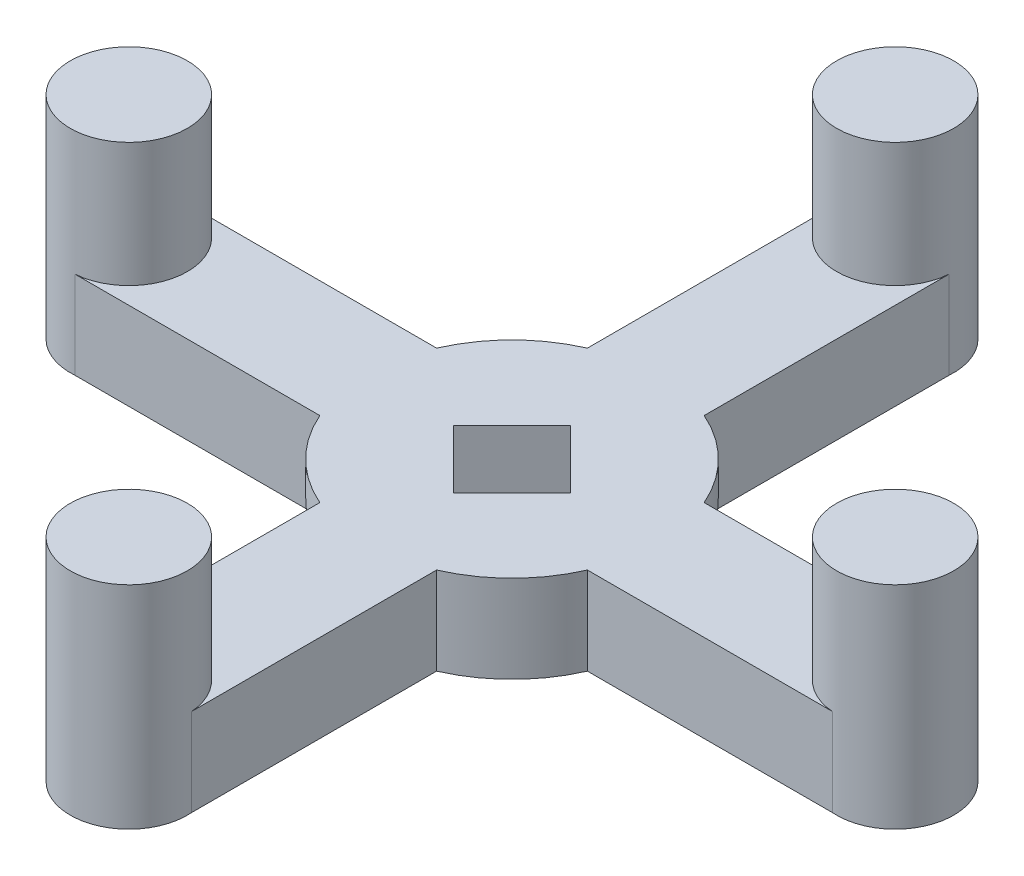
from build123d import *

# Parameters (mm, degrees)
BOSS_EXTRU_1_DEPTH           = 3
BOSS_EXTRU_1_DEPTH_BACK      = 3
BOSS_EXTRU_2_START           = -6
ESQUISSE2_R                  = 4.01172956
BOSS_EXTRU_2_DEPTH           = 14.5
R_P_TITION_CIRCULAIRE1_COUNT = 4
ENL_V_MAT_EXTRU_1_DEPTH      = 45.314721616
ENL_V_MAT_EXTRU_1_DEPTH_BACK = 45.314721616
ESQUISSE3_R                  = 1.05
ENL_V_MAT_EXTRU_2_DEPTH      = 45.314721616
ENL_V_MAT_EXTRU_2_DEPTH_BACK = 45.314721616


with BuildPart() as part:
    # Esquisse1 → Boss.-Extru.1 (new, two sides: drawn at the far end of the back side and taken through both)
    with BuildSketch(Plane(origin=(0, 0, 0), x_dir=(1, 0, 0), z_dir=(0, 1, 0)).offset(-BOSS_EXTRU_1_DEPTH_BACK)):
        with BuildLine():
            Line((4, -25.943448113), (4, -9.16515139))
            ThreePointArc((4, -9.16515139), (7.071067812, -7.071067812), (9.16515139, -4))
            Line((9.16515139, -4), (25.943448113, -4))
            ThreePointArc((25.943448113, -4), (26.25, 0), (25.943448113, 4))
            Line((25.943448113, 4), (9.16515139, 4))
            ThreePointArc((9.16515139, 4), (7.071067812, 7.071067812), (4, 9.16515139))
            Line((4, 9.16515139), (4, 25.943448113))
            ThreePointArc((4, 25.943448113), (0, 26.25), (-4, 25.943448113))
            Line((-4, 25.943448113), (-4, 9.16515139))
            ThreePointArc((-4, 9.16515139), (-7.071067812, 7.071067812), (-9.16515139, 4))
            Line((-9.16515139, 4), (-25.943448113, 4))
            ThreePointArc((-25.943448113, 4), (-26.25, 0), (-25.943448113, -4))
            Line((-25.943448113, -4), (-9.16515139, -4))
            ThreePointArc((-9.16515139, -4), (-7.071067812, -7.071067812), (-4, -9.16515139))
            Line((-4, -9.16515139), (-4, -25.943448113))
            ThreePointArc((-4, -25.943448113), (0, -26.25), (4, -25.943448113))
        make_face()
    extrude(amount=BOSS_EXTRU_1_DEPTH + BOSS_EXTRU_1_DEPTH_BACK)

    # Esquisse2 → Boss.-Extru.2 (add)
    with BuildSketch(Plane(origin=(0, 3, 0), x_dir=(1, 0, 0), z_dir=(0, 1, 0)).offset(BOSS_EXTRU_2_START)):
        with Locations((0, 26.25)):
            Circle(ESQUISSE2_R)
    boss_extru_2 = extrude(amount=BOSS_EXTRU_2_DEPTH)

    # Répétition circulaire1: Boss.-Extru.2 ×4 about axis
    r_p_tition_circulaire1_axis = Axis((0, 3, 0), (0, 1, 0))
    for i in range(1, R_P_TITION_CIRCULAIRE1_COUNT):
        add(boss_extru_2.rotate(r_p_tition_circulaire1_axis, i * 360 / R_P_TITION_CIRCULAIRE1_COUNT))

    # Esquisse3 → Enlèv. mat.-Extru.1 (cut, two sides: drawn at the far end of the back side and taken through both)
    with BuildSketch(Plane(origin=(0, 0, 0), x_dir=(-0.7071067811865477, 0, -0.7071067811865475), z_dir=(0.7071067811865475, 0, -0.7071067811865477)).offset(-ENL_V_MAT_EXTRU_1_DEPTH_BACK)):
        Circle(ESQUISSE3_R)
    extrude(amount=ENL_V_MAT_EXTRU_1_DEPTH + ENL_V_MAT_EXTRU_1_DEPTH_BACK, mode=Mode.SUBTRACT)

    # Esquisse4 → Enlèv. mat.-Extru.2 (cut, two sides: drawn at the far end of the back side and taken through both)
    with BuildSketch(Plane(origin=(0, 0, 0), x_dir=(1, 0, 0), z_dir=(0, 1, 0)).offset(-ENL_V_MAT_EXTRU_2_DEPTH_BACK)):
        Polygon((-4.000103061, 0), (0, 4.000103061), (4.000103061, 0), (0, -4.000103061), align=None)
    extrude(amount=ENL_V_MAT_EXTRU_2_DEPTH + ENL_V_MAT_EXTRU_2_DEPTH_BACK, mode=Mode.SUBTRACT)


solid = part.part
